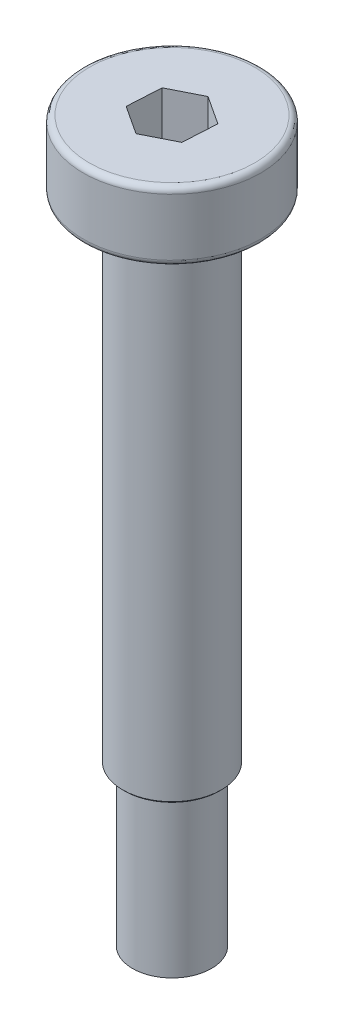
from build123d import *

# Parameters (mm, degrees)
FILLET_2_R          = 0.3
CUT_EXTRUDE_1_DEPTH = 2.4
CHAMFER_2_SIZE      = 0.1


with BuildPart() as part:
    # 草图1 → 旋转1 (revolve)
    with BuildSketch(Plane.XY):
        Polygon((0, 0), (-4.5, 0), (-4.5, -3.5), (-2.5, -3.5), (-2.5, -28.5), (-2, -28.5), (-2, -36.5), (0, -36.5), align=None)
    revolve(axis=Axis((0, -36.5, 0), (0, 1, 0)))

    # 圆角2
    fillet_2_edges = [part.edges().sort_by_distance(p)[0] for p in [
        (4.5, -3.5, 0),
        (4.5, 0, 0),
    ]]
    fillet(fillet_2_edges, radius=FILLET_2_R)

    # 草图2 → 切除-拉伸1 (cut)
    with BuildSketch(Plane(origin=(0, 0, 0), x_dir=(1, 0, 0), z_dir=(0, 1, 0))):
        Polygon((1.448722053, -0.949317867), (1.546494416, 0.779971167), (0.097772363, 1.729289035), (-1.448722053, 0.949317867), (-1.546494416, -0.779971167), (-0.097772363, -1.729289035), align=None)
    extrude(amount=-CUT_EXTRUDE_1_DEPTH, mode=Mode.SUBTRACT)

    # 倒角2
    chamfer_2_edges = [part.edges().sort_by_distance(p)[0] for p in [
        (2.5, -28.5, 0),
    ]]
    chamfer(chamfer_2_edges, length=CHAMFER_2_SIZE)


solid = part.part
